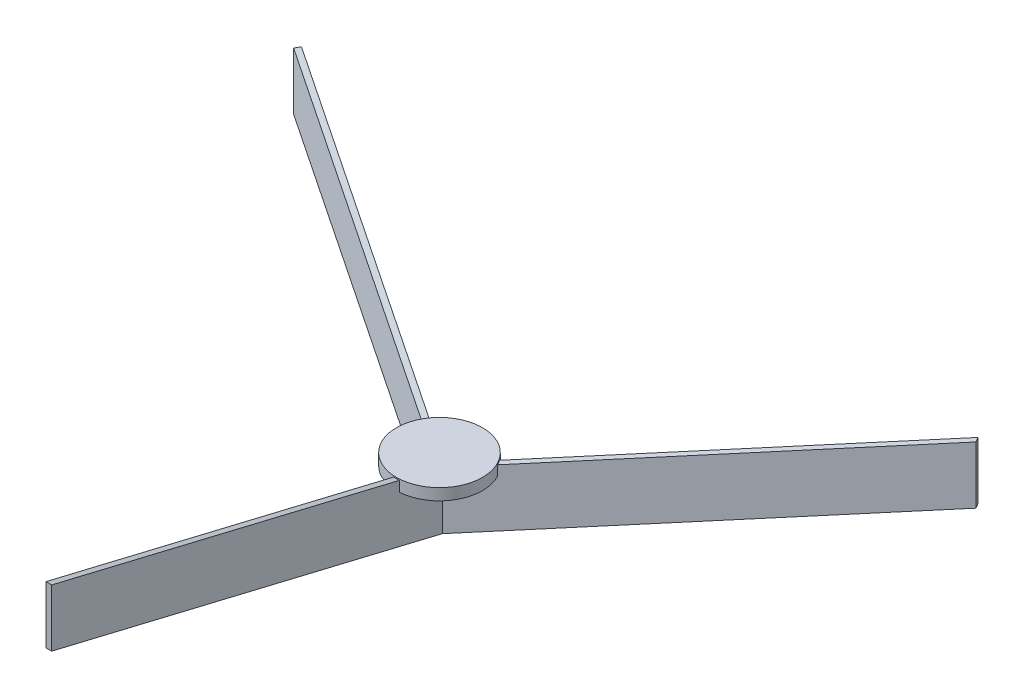
from build123d import *

# Parameters (mm, degrees)
BOSS_EXTRUDE1_DEPTH = 25.4
BOSS_EXTRUDE2_DEPTH = 1.27
CIRPATTERN3_COUNT   = 3
SKETCH3_R           = 19.05
BOSS_EXTRUDE3_DEPTH = 5.08


with BuildPart() as part:
    # Sketch1 → Boss-Extrude1 (new body)
    with BuildSketch(Plane(origin=(0, 0, 0), x_dir=(1, 0, 0), z_dir=(0, 1, 0))):
        Polygon((-1.27, 0), (0, 2.199704526), (1.27, 0), align=None)
    extrude(amount=BOSS_EXTRUDE1_DEPTH)

    # Sketch2 → Boss-Extrude2 (add, symmetric)
    with BuildSketch(Plane(origin=(0, 0, 0), x_dir=(0, 0, -1), z_dir=(1, 0, 0))):
        Polygon((0, 0), (-172.909241249, 41.415387125), (-172.909241249, 66.815387125), (0, 25.4), align=None)
    boss_extrude2 = extrude(amount=BOSS_EXTRUDE2_DEPTH, both=True)

    # CirPattern3: Boss-Extrude2 ×3 about axis
    cirpattern3_axis = Axis((0, 25.4, -0.733234842), (0, 1, 0))
    for i in range(1, CIRPATTERN3_COUNT):
        add(boss_extrude2.rotate(cirpattern3_axis, i * 360 / CIRPATTERN3_COUNT))

    # Sketch3 → Boss-Extrude3 (add)
    with BuildSketch(Plane(origin=(0, 25.4, 0), x_dir=(1, 0, 0), z_dir=(0, 1, 0))):
        Circle(SKETCH3_R)
    extrude(amount=BOSS_EXTRUDE3_DEPTH)


solid = part.part
